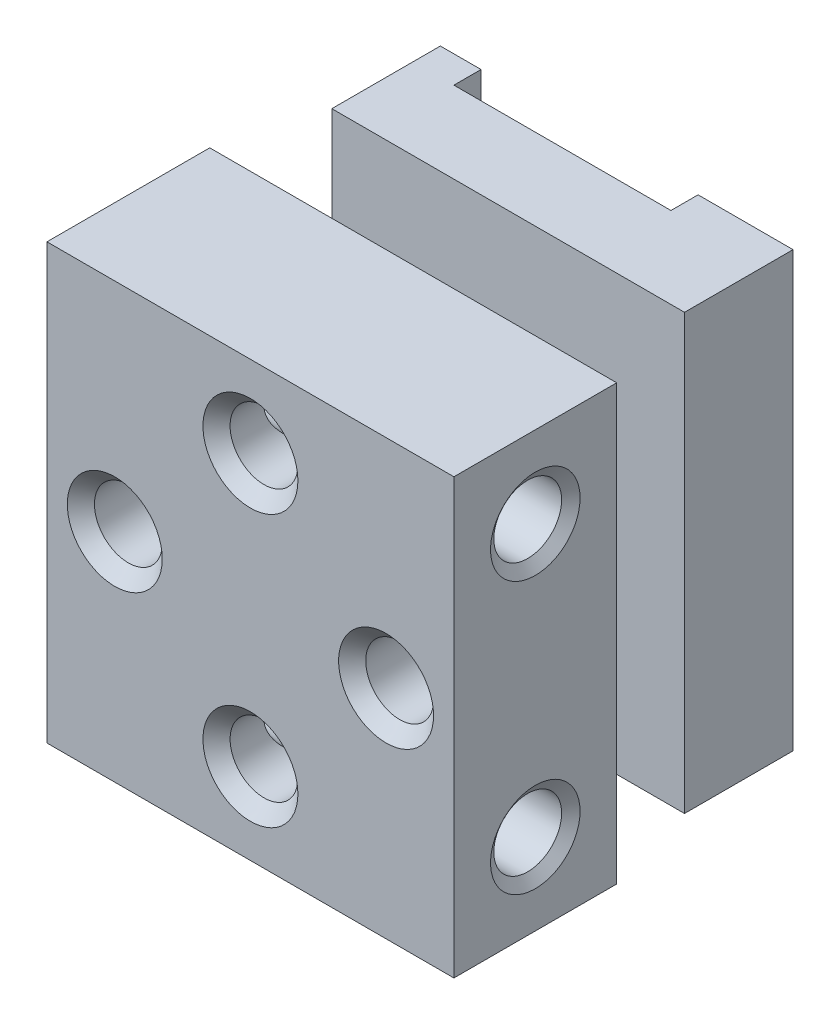
from build123d import *

# Parameters (mm, degrees)
SKETCH_1_W                  = 15
SKETCH_1_H                  = 16
EXTRUDE_1_DEPTH             = 13.5
SKETCH_2_W                  = 1
SKETCH_2_H                  = 16
CUT_EXTRUDE_2_DEPTH         = 7.5
SKETCH_4_W                  = 3.5
SKETCH_4_H                  = 5
CUT_EXTRUDE_4_DEPTH         = 15
SKETCH_5_W                  = 3.5
SKETCH_5_H                  = 3.5
CUT_EXTRUDE_9_DEPTH         = 6
CUT_EXTRUDE_10_REACH        = 13
SKETCH_6_W                  = 2.5
SKETCH_6_H                  = 1
SKETCH_7_W                  = 1
SKETCH_7_H                  = 2.5
CUT_EXTRUDE_11_DEPTH        = 11.5
SKETCH_8_W                  = 8
SKETCH_8_H                  = 1
CUT_EXTRUDE_12_DEPTH        = 17
HOLE_WIZARD_M31_AT_2_COUNT  = 2
HOLE_WIZARD_M31_AT_2_PITCH  = 10
HOLE_WIZARD_M31_AT_3_COUNT  = 2
HOLE_WIZARD_M31_AT_3_PITCH  = 7.071067812
HOLE_WIZARD_M31_AT_4_COUNT  = 2
HOLE_WIZARD_M31_AT_4_PITCH  = 7.071067812
HOLE_WIZARD_M33_D           = 2.5
HOLE_WIZARD_M33_DEPTH       = 7.5
HOLE_WIZARD_M33_CSINK_D     = 3.3
HOLE_WIZARD_M33_CSINK_ANGLE = 110
HOLE_WIZARD_M33_TIP         = 0.751075774
SKETCH_11_W                 = 7.5
SKETCH_11_H                 = 3.5
HOLE_WIZARD_M35_D           = 2.5
HOLE_WIZARD_M35_DEPTH       = 7.5
HOLE_WIZARD_M35_CSINK_D     = 3.3
HOLE_WIZARD_M35_CSINK_ANGLE = 110
HOLE_WIZARD_M35_TIP         = 0.751075774


with BuildPart() as part:
    # Эскиз1 → Вытянуть1 (new body)
    with BuildSketch(Plane.XY):
        Rectangle(SKETCH_1_W, SKETCH_1_H)
    extrude(amount=EXTRUDE_1_DEPTH)

    # Эскиз2 → Вырез-Вытянуть2 (cut)
    with BuildSketch(Plane(origin=(0, 0, 0), x_dir=(-1, 0, 0), z_dir=(0, 0, -1))):
        with Locations((7, 0)):
            Rectangle(SKETCH_2_W, SKETCH_2_H)
        with Locations((-7, 0)):
            Rectangle(SKETCH_2_W, SKETCH_2_H)
    extrude(amount=-CUT_EXTRUDE_2_DEPTH, mode=Mode.SUBTRACT)

    # Эскиз4 → Вырез-Вытянуть4 (cut, through all)
    with BuildSketch(Plane.ZY.offset(6.5)):
        with Locations((5.75, 5.5)):
            Rectangle(SKETCH_4_W, SKETCH_4_H)
        with Locations((5.75, -5.5)):
            Rectangle(SKETCH_4_W, SKETCH_4_H)
    extrude(amount=-CUT_EXTRUDE_4_DEPTH, mode=Mode.SUBTRACT)

    # Эскиз5 → Вырез-Вытянуть9 (cut)
    with BuildSketch(Plane(origin=(0, 3, 0), x_dir=(-1, 0, 0), z_dir=(0, 1, 0))):
        with Locations((-4.75, 5.75)):
            Rectangle(SKETCH_5_W, SKETCH_5_H)
        with Locations((4.75, 5.75)):
            Rectangle(SKETCH_5_W, SKETCH_5_H)
    extrude(amount=-CUT_EXTRUDE_9_DEPTH, mode=Mode.SUBTRACT)

    # Эскиз6 → Вырез-Вытянуть10 (cut, up to next)
    with BuildSketch(Plane(origin=(0, 3, 0), x_dir=(-1, 0, 0), z_dir=(0, 1, 0)), mode=Mode.PRIVATE) as cut_extrude_10_sk1:
        with Locations((-1.75, 7)):
            Rectangle(SKETCH_6_W, SKETCH_6_H)
    cut_extrude_10_tool1 = extrude(cut_extrude_10_sk1.sketch, amount=-CUT_EXTRUDE_10_REACH, mode=Mode.PRIVATE) & part.part
    add(cut_extrude_10_tool1.solids().sort_by_distance((1.75, 3, 7))[0], mode=Mode.SUBTRACT)
    # Эскиз6 → Вырез-Вытянуть10 (cut, up to next)
    with BuildSketch(Plane(origin=(0, 3, 0), x_dir=(-1, 0, 0), z_dir=(0, 1, 0)), mode=Mode.PRIVATE) as cut_extrude_10_sk2:
        with Locations((1.75, 7)):
            Rectangle(SKETCH_6_W, SKETCH_6_H)
    cut_extrude_10_tool2 = extrude(cut_extrude_10_sk2.sketch, amount=-CUT_EXTRUDE_10_REACH, mode=Mode.PRIVATE) & part.part
    add(cut_extrude_10_tool2.solids().sort_by_distance((-1.75, 3, 7))[0], mode=Mode.SUBTRACT)

    # Эскиз7 → Вырез-Вытянуть11 (cut, through all)
    with BuildSketch(Plane(origin=(3, 0, 0), x_dir=(0, 0, -1), z_dir=(1, 0, 0))):
        with Locations((-4.5, 1.75)):
            Rectangle(SKETCH_7_W, SKETCH_7_H)
        with Locations((-4.5, -1.75)):
            Rectangle(SKETCH_7_W, SKETCH_7_H)
    extrude(amount=-CUT_EXTRUDE_11_DEPTH, mode=Mode.SUBTRACT)

    # Эскиз8 → Вырез-Вытянуть12 (cut, through all)
    with BuildSketch(Plane(origin=(0, 8, 0), x_dir=(-1, 0, 0), z_dir=(0, 1, 0))):
        with Locations((1, 0.5)):
            Rectangle(SKETCH_8_W, SKETCH_8_H)
    extrude(amount=-CUT_EXTRUDE_12_DEPTH, mode=Mode.SUBTRACT)

    # Эскиз9 → Отверстие обработанное метчиком M31 (revolve, cut)
    with BuildSketch(Plane(origin=(0, -5, 13.5), x_dir=(0, -1, 0), z_dir=(1, 0, 0))):
        Polygon((0, 0), (0, 6), (1.75, 6), (1.25, 5.5), (1.25, 0.5), (1.75, 0), align=None)
    hole_wizard_m31 = revolve(axis=Axis((0, -5, 19.85), (0, 0, -1)), mode=Mode.SUBTRACT)

    # Отверстие обработанное метчиком M31 at 2: Отверстие обработанное метчиком M31 ×2
    with Locations(*[(0, i * HOLE_WIZARD_M31_AT_2_PITCH, 0) for i in range(1, HOLE_WIZARD_M31_AT_2_COUNT)]):
        add(hole_wizard_m31, mode=Mode.SUBTRACT)

    # Отверстие обработанное метчиком M31 at 3: Отверстие обработанное метчиком M31 ×2
    with Locations(*[Vector(0.707106781, 0.707106781, 0) * (i * HOLE_WIZARD_M31_AT_3_PITCH) for i in range(1, HOLE_WIZARD_M31_AT_3_COUNT)]):
        add(hole_wizard_m31, mode=Mode.SUBTRACT)

    # Отверстие обработанное метчиком M31 at 4: Отверстие обработанное метчиком M31 ×2
    with Locations(*[Vector(-0.707106781, 0.707106781, 0) * (i * HOLE_WIZARD_M31_AT_4_PITCH) for i in range(1, HOLE_WIZARD_M31_AT_4_COUNT)]):
        add(hole_wizard_m31, mode=Mode.SUBTRACT)

    # Отверстие обработанное метчиком M33
    with Locations(Plane(origin=(-7.5, 5, 10.5), x_dir=(0, 0, -1), z_dir=(-1, 0, 0))):
        with Locations((0, 0), (0, 10)):
            CounterSinkHole(HOLE_WIZARD_M33_D / 2, HOLE_WIZARD_M33_CSINK_D / 2, depth=HOLE_WIZARD_M33_DEPTH, counter_sink_angle=HOLE_WIZARD_M33_CSINK_ANGLE)
            with Locations((0, 0, -(HOLE_WIZARD_M33_DEPTH + HOLE_WIZARD_M33_TIP / 2))):  # 118° drill point
                Cone(0, HOLE_WIZARD_M33_D / 2, HOLE_WIZARD_M33_TIP, mode=Mode.SUBTRACT)

    # Эскиз11 → Вырез-Повернуть1 (revolve, cut)
    with BuildSketch(Plane(origin=(0, 0, 0), x_dir=(1, 0, 0), z_dir=(0, 1, 0))):
        with Locations((6.75, -5.75)):
            Rectangle(SKETCH_11_W, SKETCH_11_H)
    revolve(axis=Axis((0, 0, 0), (0, 0, 1)), mode=Mode.SUBTRACT)

    # Отверстие обработанное метчиком M35
    with Locations(Plane(origin=(7.5, 6.867633096, -0.651107824), x_dir=(0, 0, -1), z_dir=(1, 0, 0))):
        with Locations((-11.151107824, -1.867633096), (-11.151107824, -11.867633096)):
            CounterSinkHole(HOLE_WIZARD_M35_D / 2, HOLE_WIZARD_M35_CSINK_D / 2, depth=HOLE_WIZARD_M35_DEPTH, counter_sink_angle=HOLE_WIZARD_M35_CSINK_ANGLE)
            with Locations((0, 0, -(HOLE_WIZARD_M35_DEPTH + HOLE_WIZARD_M35_TIP / 2))):  # 118° drill point
                Cone(0, HOLE_WIZARD_M35_D / 2, HOLE_WIZARD_M35_TIP, mode=Mode.SUBTRACT)


solid = part.part
